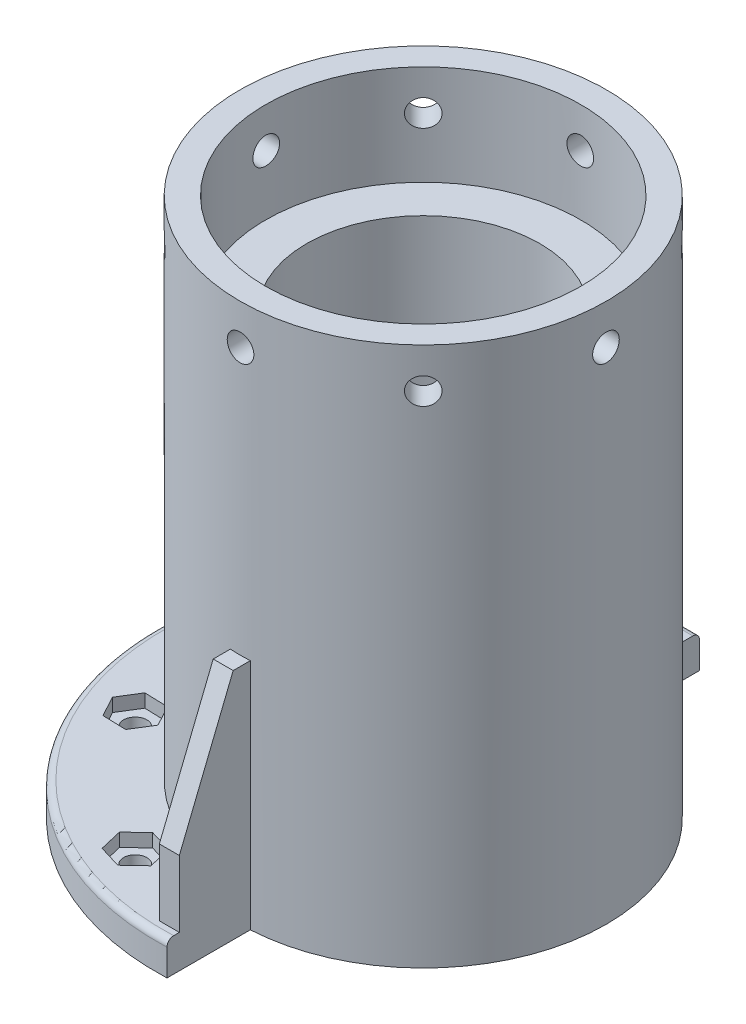
from build123d import *

# Parameters (mm, degrees)
SKETCH1_R                = 27.5
SKETCH1_R_2              = 23.65
BOSS_EXTRUDE1_DEPTH      = 30
SKETCH2_R                = 2
CUT_EXTRUDE1_DEPTH       = 28.5
CIRPATTERN1_COUNT        = 4
CIRPATTERN1_ANGLE        = 135
SKETCH3_R                = 27.5
SKETCH3_R_2              = 23.65
BOSS_EXTRUDE2_DEPTH      = 51
BOSS_EXTRUDE3_DEPTH      = 5
SKETCH6_W                = 3
SKETCH6_H                = 12
SKETCH6_W_2              = 12
SKETCH6_H_2              = 3
BOSS_EXTRUDE4_DEPTH      = 30
CHAMFER1_SIZE            = 20
CHAMFER1_SIZE2           = 8.080524517
CHAMFER1_PART_2_SIZE     = 20
CHAMFER1_PART_2_SIZE2    = 8.080524517
CHAMFER1_PART_3_SIZE     = 20
CHAMFER1_PART_3_SIZE2    = 8.080524517
SKETCH7_R                = 1.75
CUT_EXTRUDE2_DEPTH       = 6.0000001
CUT_EXTRUDE3_DEPTH       = 2
CIRPATTERN2_COUNT        = 4
CIRPATTERN2_ANGLE        = 135
FILLET1_R                = 1
SKETCH9_R                = 26.233260483
SKETCH9_R_2              = 17.5
BOSS_EXTRUDE5_DEPTH      = 15
BOSS_EXTRUDE5_DEPTH_BACK = 51


with BuildPart() as part:
    # Sketch1 → Boss-Extrude1 (new body)
    with BuildSketch(Plane(origin=(0, 0, 0), x_dir=(1, 0, 0), z_dir=(0, 1, 0))):
        Circle(SKETCH1_R)
        Circle(SKETCH1_R_2, mode=Mode.SUBTRACT)
    extrude(amount=BOSS_EXTRUDE1_DEPTH)

    # Sketch2 → Cut-Extrude1 (cut, symmetric)
    with BuildSketch(Plane.XY):
        with Locations((0, 24)):
            Circle(SKETCH2_R)
    cut_extrude1 = extrude(amount=CUT_EXTRUDE1_DEPTH, both=True, mode=Mode.SUBTRACT)

    # CirPattern1: Cut-Extrude1 ×4 about axis
    cirpattern1_axis = Axis((0, 30, 0), (0, 1, 0))
    for i in range(1, CIRPATTERN1_COUNT):
        add(cut_extrude1.rotate(cirpattern1_axis, i * CIRPATTERN1_ANGLE / (CIRPATTERN1_COUNT - 1)), mode=Mode.SUBTRACT)

    # Sketch3 → Boss-Extrude2 (add)
    with BuildSketch(Plane.XZ):
        Circle(SKETCH3_R)
        Circle(SKETCH3_R_2, mode=Mode.SUBTRACT)
    extrude(amount=BOSS_EXTRUDE2_DEPTH)

    # Sketch4 → Boss-Extrude3 (add)
    with BuildSketch(Plane.XZ.offset(51)):
        with BuildLine():
            Line((1.5, 27.459060435), (1.5, 39.971865105))
            ThreePointArc((1.5, 39.971865105), (-40, 0), (1.5, -39.971865105))
            Line((1.5, -39.971865105), (1.5, -27.459060435))
            ThreePointArc((1.5, -27.459060435), (-27.5, 0), (1.5, 27.459060435))
        make_face()
    extrude(amount=-BOSS_EXTRUDE3_DEPTH)

    # Sketch6 → Boss-Extrude4 (add)
    with BuildSketch(Plane(origin=(0, -46, 0), x_dir=(1, 0, 0), z_dir=(0, 1, 0))):
        with Locations((0, 30.644528231)):
            Rectangle(SKETCH6_W, SKETCH6_H)
        with Locations((-30.709825096, -0.28052704)):
            Rectangle(SKETCH6_W_2, SKETCH6_H_2)
        with Locations((0, -32.114539573)):
            Rectangle(SKETCH6_W, SKETCH6_H)
    extrude(amount=BOSS_EXTRUDE4_DEPTH)

    # Chamfer1
    chamfer1_edges = [part.edges().sort_by_distance(p)[0] for p in [
        (0, -16, -36.644528231),
    ]]
    chamfer1_side = [part.faces().sort_by_distance(p)[0] for p in [
        (0, -31, -36.644528231),
    ]]
    chamfer(chamfer1_edges, length=CHAMFER1_SIZE, length2=CHAMFER1_SIZE2, reference=chamfer1_side[0])

    # Chamfer1 part 2
    chamfer1_part_2_edges = [part.edges().sort_by_distance(p)[0] for p in [
        (-36.709825096, -16, 0.28052704),
    ]]
    chamfer1_part_2_side = [part.faces().sort_by_distance(p)[0] for p in [
        (-36.709825096, -31, 0.28052704),
    ]]
    chamfer(chamfer1_part_2_edges, length=CHAMFER1_PART_2_SIZE, length2=CHAMFER1_PART_2_SIZE2, reference=chamfer1_part_2_side[0])

    # Chamfer1 part 3
    chamfer1_part_3_edges = [part.edges().sort_by_distance(p)[0] for p in [
        (0, -16, 38.114539573),
    ]]
    chamfer1_part_3_side = [part.faces().sort_by_distance(p)[0] for p in [
        (0, -31, 38.114539573),
    ]]
    chamfer(chamfer1_part_3_edges, length=CHAMFER1_PART_3_SIZE, length2=CHAMFER1_PART_3_SIZE2, reference=chamfer1_part_3_side[0])

    # Sketch7 → Cut-Extrude2 (cut, through all)
    with BuildSketch(Plane(origin=(0, -46, 0), x_dir=(1, 0, 0), z_dir=(0, 1, 0))):
        with Locations((-12.663510369, 30.572418481)):
            Circle(SKETCH7_R)
    cut_extrude2 = extrude(amount=-CUT_EXTRUDE2_DEPTH, mode=Mode.SUBTRACT)

    # Sketch8 → Cut-Extrude3 (cut)
    with BuildSketch(Plane(origin=(0, -46, 0), x_dir=(1, 0, 0), z_dir=(0, 1, 0))):
        Polygon((-9.561603451, 32.24020348), (-12.556901088, 34.092641172), (-15.658808006, 32.424856172), (-15.765417287, 28.904633481), (-12.770119651, 27.05219579), (-9.668212733, 28.719980789), align=None)
    cut_extrude3 = extrude(amount=-CUT_EXTRUDE3_DEPTH, mode=Mode.SUBTRACT)

    # CirPattern2: Cut-Extrude2, Cut-Extrude3 ×4 about axis
    cirpattern2_axis = Axis((0, 0, 0), (0, 1, 0))
    for i in range(1, CIRPATTERN2_COUNT):
        add(cut_extrude2.rotate(cirpattern2_axis, i * CIRPATTERN2_ANGLE / (CIRPATTERN2_COUNT - 1)), mode=Mode.SUBTRACT)
        add(cut_extrude3.rotate(cirpattern2_axis, i * CIRPATTERN2_ANGLE / (CIRPATTERN2_COUNT - 1)), mode=Mode.SUBTRACT)

    # Fillet1
    fillet1_edges = [part.edges().sort_by_distance(p)[0] for p in [
        (-40, -46, 0),
    ]]
    fillet(fillet1_edges, radius=FILLET1_R)

    # Sketch9 → Boss-Extrude5 (add, two sides)
    with BuildSketch(Plane(origin=(0, 0, 0), x_dir=(1, 0, 0), z_dir=(0, 1, 0))) as boss_extrude5_sk:
        Circle(SKETCH9_R)
        Circle(SKETCH9_R_2, mode=Mode.SUBTRACT)
    extrude(amount=BOSS_EXTRUDE5_DEPTH)
    extrude(boss_extrude5_sk.sketch, amount=-BOSS_EXTRUDE5_DEPTH_BACK)


solid = part.part
